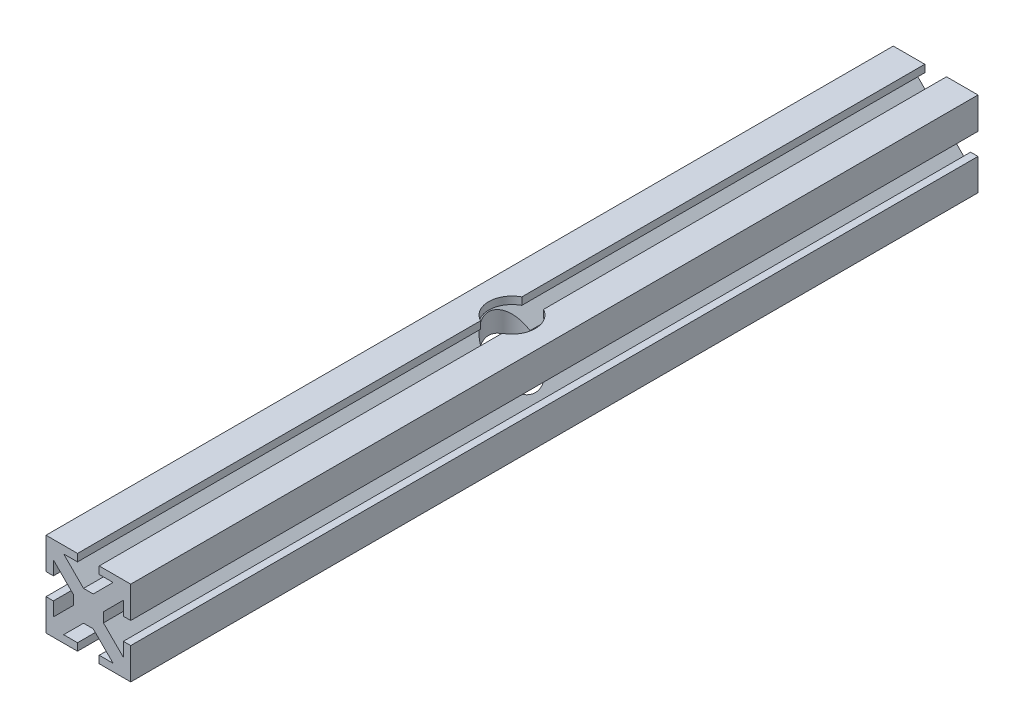
from build123d import *

# Parameters (mm, degrees)
SKETCH1_W           = 25.4
SKETCH1_H           = 25.4
BOSS_EXTRUDE2_DEPTH = 254
CUT_EXTRUDE1_DEPTH  = 254
CUT_EXTRUDE2_DEPTH  = 250


with BuildPart() as part:
    # Sketch1 → Boss-Extrude2 (new body)
    with BuildSketch(Plane.XY):
        Rectangle(SKETCH1_W, SKETCH1_H)
    extrude(amount=BOSS_EXTRUDE2_DEPTH)

    # Sketch3 → Cut-Extrude1 (cut)
    with BuildSketch(Plane.XY.offset(254)):
        Polygon((-4.5212, -1.4482), (-4.5212, 1.4482), (-10.4902, 7.4172), (-10.4902, 3.2512), (-12.7, 3.2512), (-12.7, -3.2512), (-10.4902, -3.2512), (-10.4902, -7.4172), align=None)
        Polygon((-7.4172, 10.4902), (-1.4482, 4.5212), (1.4482, 4.5212), (7.4172, 10.4902), (3.2512, 10.4902), (3.2512, 12.7), (0, 12.7), (-3.2512, 12.7), (-3.2512, 10.4902), align=None)
        Polygon((10.4902, 7.4172), (4.5212, 1.4482), (4.5212, -1.4482), (10.4902, -7.4172), (10.4902, -3.2512), (12.7, -3.2512), (12.7, 3.2512), (10.4902, 3.2512), align=None)
        Polygon((1.4482, -4.5212), (-1.4482, -4.5212), (-7.4172, -10.4902), (-3.2512, -10.4902), (-3.2512, -12.7), (3.2512, -12.7), (3.2512, -10.4902), (7.4172, -10.4902), align=None)
    extrude(amount=-CUT_EXTRUDE1_DEPTH, mode=Mode.SUBTRACT)

    # Sketch5 → Cut-Extrude2 (cut)
    with BuildSketch(Plane(origin=(0, 12.7, 0), x_dir=(1, 0, 0), z_dir=(0, 1, 0))):
        with BuildLine():
            ThreePointArc((-3.2512, -120.800830817), (-5.989924874, -123.377735515), (-7, -127))
            Line((-7, -127), (-3.2512, -127))
            Line((-3.2512, -127), (-3.2512, -120.800830817))
        make_face()
        with BuildLine():
            Line((-3.2512, -127), (-7, -127))
            ThreePointArc((-7, -127), (-5.989924874, -130.622264485), (-3.2512, -133.199169183))
            Line((-3.2512, -133.199169183), (-3.2512, -127))
        make_face()
        with BuildLine():
            Line((-3.2512, -120.800830817), (-3.2512, -127))
            Line((-3.2512, -127), (7, -127))
            ThreePointArc((7, -127), (3.622264485, -121.010075126), (-3.2512, -120.800830817))
        make_face()
        with BuildLine():
            Line((7, -127), (-3.2512, -127))
            Line((-3.2512, -127), (-3.2512, -133.199169183))
            ThreePointArc((-3.2512, -133.199169183), (3.622264485, -132.989924874), (7, -127))
        make_face()
    extrude(amount=-CUT_EXTRUDE2_DEPTH, mode=Mode.SUBTRACT)


solid = part.part
